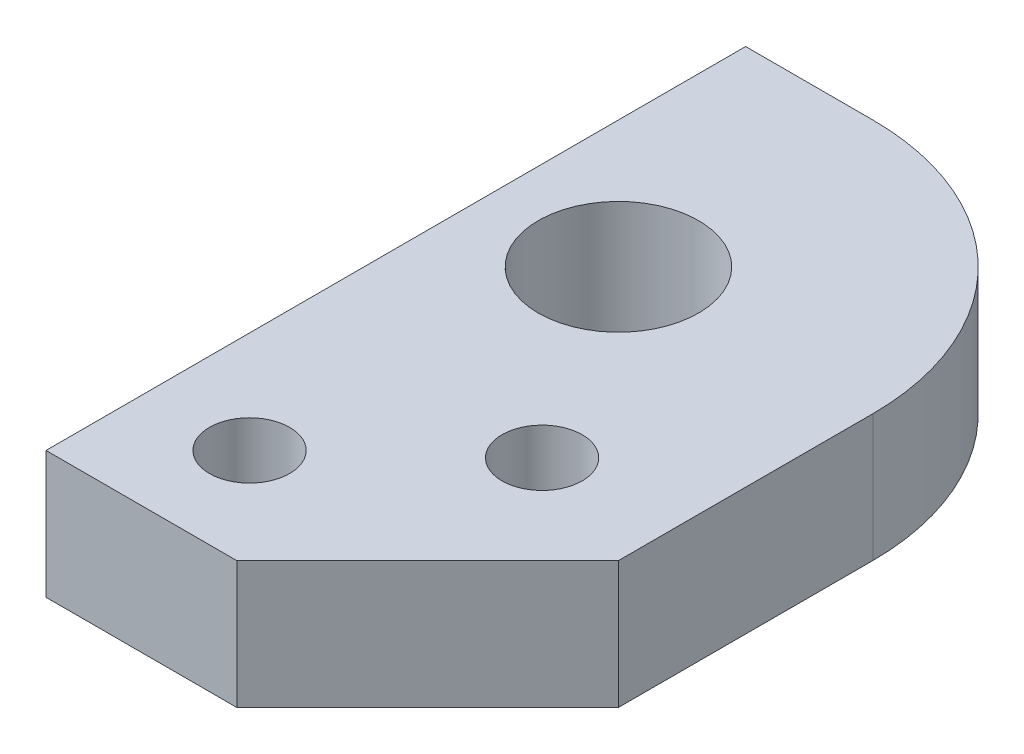
from build123d import *

# Parameters (mm, degrees)
SKETCH2_R           = 2
SKETCH2_R_2         = 4.0005
BOSS_EXTRUDE1_DEPTH = 6.35


with BuildPart() as part:
    # Sketch2 → Boss-Extrude1 (new body)
    with BuildSketch(Plane(origin=(0, 0, 0), x_dir=(1, 0, 0), z_dir=(0, 1, 0))):
        with BuildLine():
            Line((6.35, 127), (12.7, 127))
            ThreePointArc((12.7, 127), (21.680256121, 123.280256121), (25.4, 114.3))
            Line((25.4, 114.3), (25.4, 101.6))
            Line((25.4, 101.6), (15.875, 92.075))
            Line((15.875, 92.075), (6.35, 92.075))
            Line((6.35, 92.075), (6.35, 101.6))
            Line((6.35, 101.6), (6.35, 127))
        make_face()
        with Locations((11.43, 97.155)):
            Circle(SKETCH2_R, mode=Mode.SUBTRACT)
        with Locations((19.05, 104.14)):
            Circle(SKETCH2_R, mode=Mode.SUBTRACT)
        with Locations((12.7, 114.3)):
            Circle(SKETCH2_R_2, mode=Mode.SUBTRACT)
    extrude(amount=BOSS_EXTRUDE1_DEPTH)


solid = part.part
